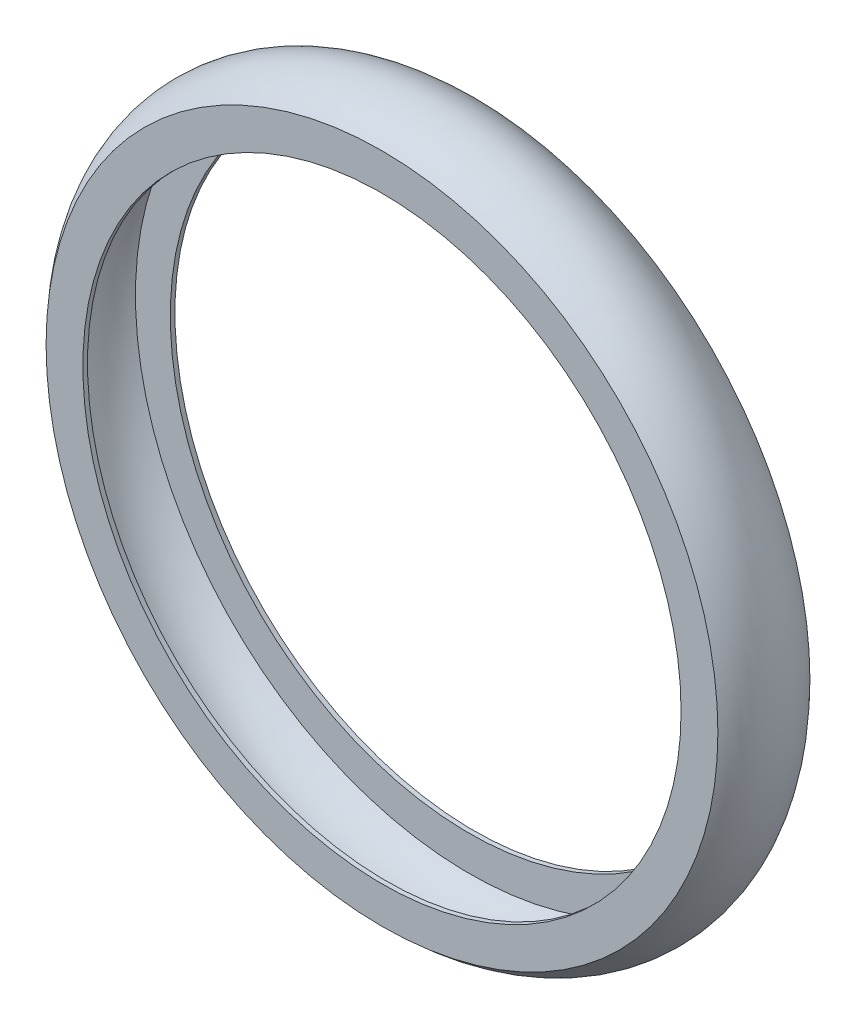
from build123d import *


with BuildPart() as part:
    # Sketch1 → Revolve2 (revolve)
    with BuildSketch(Plane(origin=(0, 0, 0), x_dir=(0, 0, -1), z_dir=(1, 0, 0))):
        with BuildLine():
            Line((-50.8, 165.1), (-50.8, 185.42))
            ThreePointArc((-50.8, 185.42), (-25.4, 195.941024484), (0, 185.42))
            Line((0, 185.42), (0, 165.1))
            Line((0, 165.1), (-2.54, 165.1))
            Line((-2.54, 165.1), (-2.54, 184.345155613))
            ThreePointArc((-2.54, 184.345155613), (-25.4, 193.401024484), (-48.26, 184.345155613))
            Line((-48.26, 184.345155613), (-48.26, 165.1))
            Line((-48.26, 165.1), (-50.8, 165.1))
        make_face()
    revolve(axis=Axis((0, 0, 75.421455939), (0, 0, -1)))


solid = part.part
